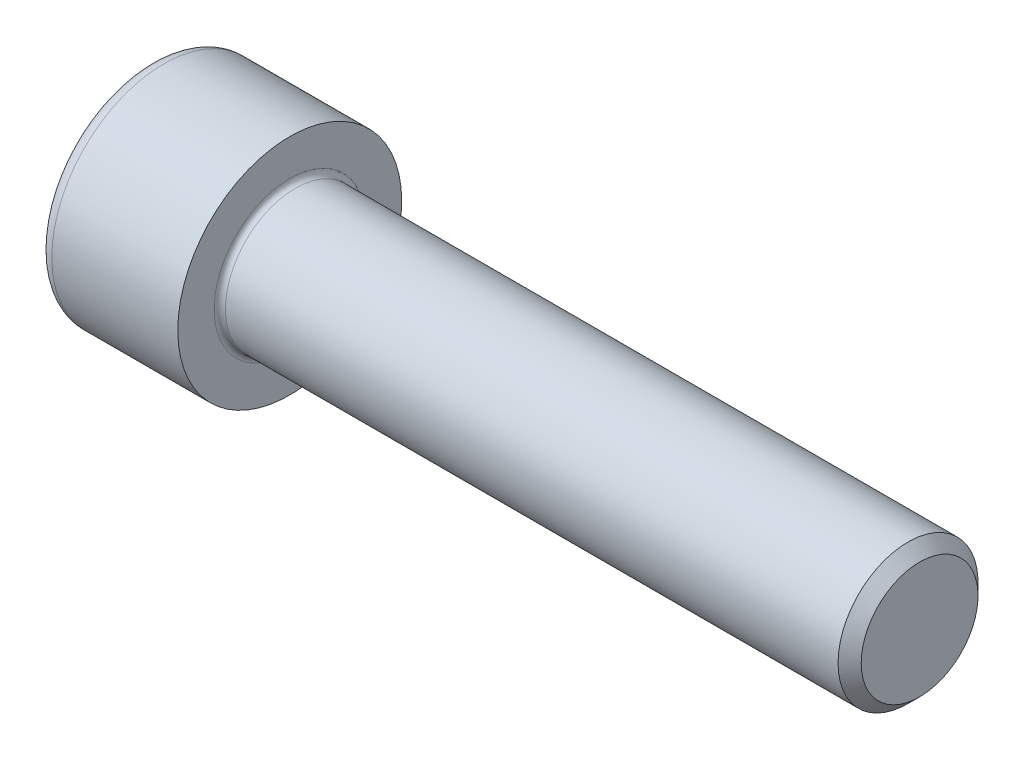
from build123d import *

# Parameters (mm, degrees)
FILLET1_R   = 0.4
FILLET2_R   = 1
HEX_2_DEPTH = 5


with BuildPart() as part:
    # BodySke → Base-Revolve (revolve)
    with BuildSketch(Plane.XY):
        Polygon((0, 0), (0, 8), (10, 8), (10, 5), (54.172, 5), (55, 4.172), (55, 0), align=None)
    revolve(axis=Axis((-31.75, 0, 0), (1, 0, 0)))

    # Fillet1
    fillet1_edges = [part.edges().sort_by_distance(p)[0] for p in [
        (10, -5, 0),
    ]]
    fillet(fillet1_edges, radius=FILLET1_R)

    # Fillet2
    fillet2_edges = [part.edges().sort_by_distance(p)[0] for p in [
        (0, -8, 0),
    ]]
    fillet(fillet2_edges, radius=FILLET2_R)

    # Sketch2 → Hex-PreBroach (revolve, cut)
    with BuildSketch(Plane.XY):
        Polygon((0, 4.0125), (5, 4.0125), (7.316617955, 0), (0, 0), align=None)
    revolve(axis=Axis((0, 0, 0), (1, 0, 0)), mode=Mode.SUBTRACT)

    # Sketch3 → Hex 2 (cut)
    with BuildSketch(Plane(origin=(0, 0, 0), x_dir=(0, 0.5, 0.866025404), z_dir=(-1, 0, 0))):
        Polygon((2.316617955, 4.0125), (-2.316617955, 4.0125), (-4.63323591, 0), (-2.316617955, -4.0125), (2.316617955, -4.0125), (4.63323591, 0), align=None)
    extrude(amount=-HEX_2_DEPTH, mode=Mode.SUBTRACT)


solid = part.part
